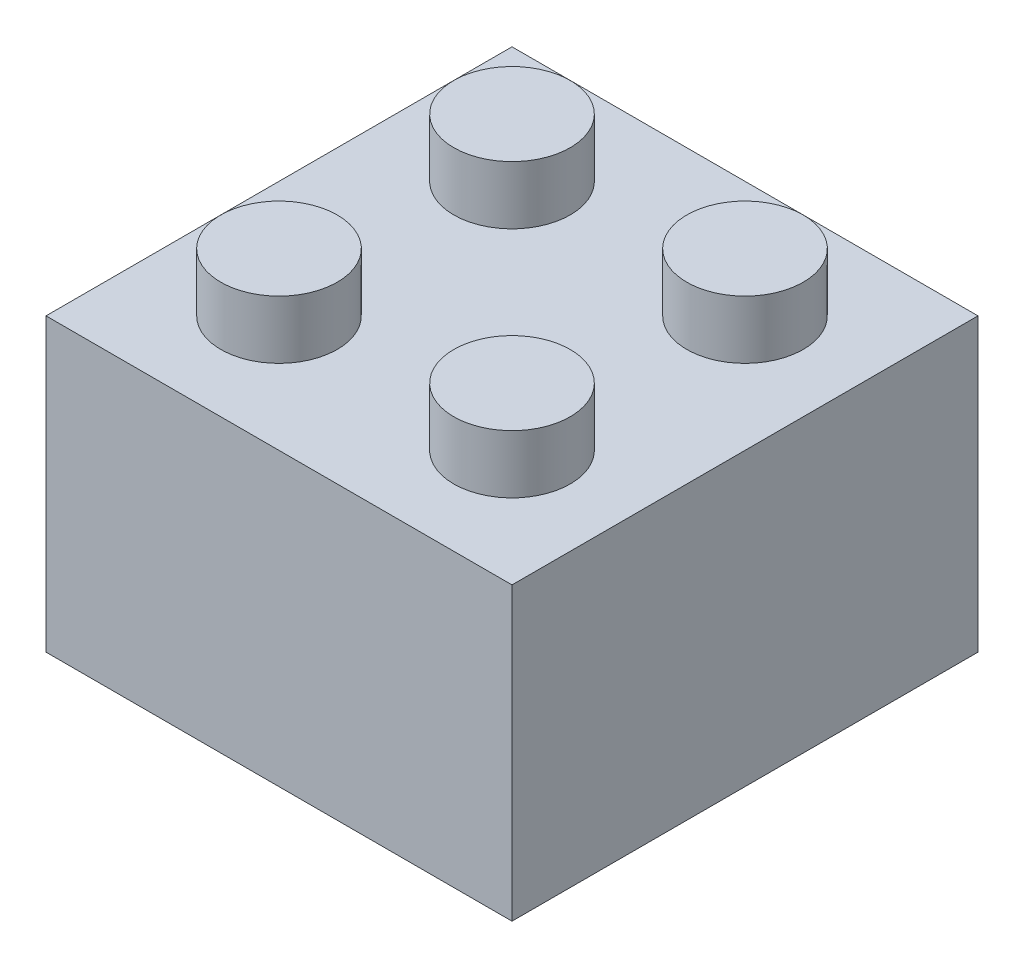
from build123d import *

# Parameters (mm, degrees)
SKETCH2_W           = 16
SKETCH2_H           = 16
BOSS_EXTRUDE1_DEPTH = 10
SKETCH3_R           = 2
BOSS_EXTRUDE2_DEPTH = 2
SHELL2_T            = -1
SKETCH4_R           = 2.7
SKETCH4_R_2         = 1.7
BOSS_EXTRUDE3_DEPTH = 9


with BuildPart() as part:
    # Sketch2 → Boss-Extrude1 (new body)
    with BuildSketch(Plane(origin=(0, 0, 0), x_dir=(1, 0, 0), z_dir=(0, 1, 0))):
        Rectangle(SKETCH2_W, SKETCH2_H)
    extrude(amount=BOSS_EXTRUDE1_DEPTH)

    # Sketch3 → Boss-Extrude2 (add)
    with BuildSketch(Plane(origin=(0, 10, 0), x_dir=(1, 0, 0), z_dir=(0, 1, 0))):
        with Locations((-4, 4)):
            Circle(SKETCH3_R)
        with Locations((4, 4)):
            Circle(SKETCH3_R)
        with Locations((4, -4)):
            Circle(SKETCH3_R)
        with Locations((-4, -4)):
            Circle(SKETCH3_R)
    extrude(amount=BOSS_EXTRUDE2_DEPTH)

    # Shell2
    shell2_openings = [part.faces().sort_by_distance(p)[0] for p in [
        (0, 0, 0),
    ]]
    offset(amount=SHELL2_T, openings=shell2_openings, kind=Kind.INTERSECTION)

    # Sketch4 → Boss-Extrude3 (add)
    with BuildSketch(Plane.XZ.offset(-9)):
        Circle(SKETCH4_R)
        Circle(SKETCH4_R_2, mode=Mode.SUBTRACT)
    extrude(amount=BOSS_EXTRUDE3_DEPTH)


solid = part.part
